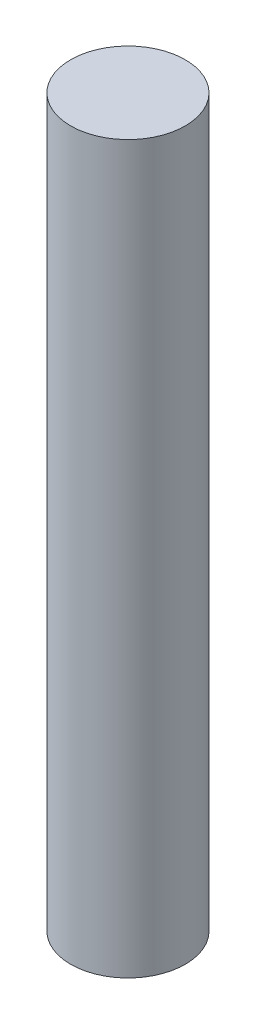
from build123d import *

# Parameters (mm, degrees)
ESBO_O1_R                = 7.5
RESSALTO_EXTRUS_O1_DEPTH = 95


with BuildPart() as part:
    # Esboço1 → Ressalto-extrusão1 (new body)
    with BuildSketch(Plane(origin=(0, 0, 0), x_dir=(1, 0, 0), z_dir=(0, 1, 0))):
        Circle(ESBO_O1_R)
    extrude(amount=RESSALTO_EXTRUS_O1_DEPTH)


solid = part.part
